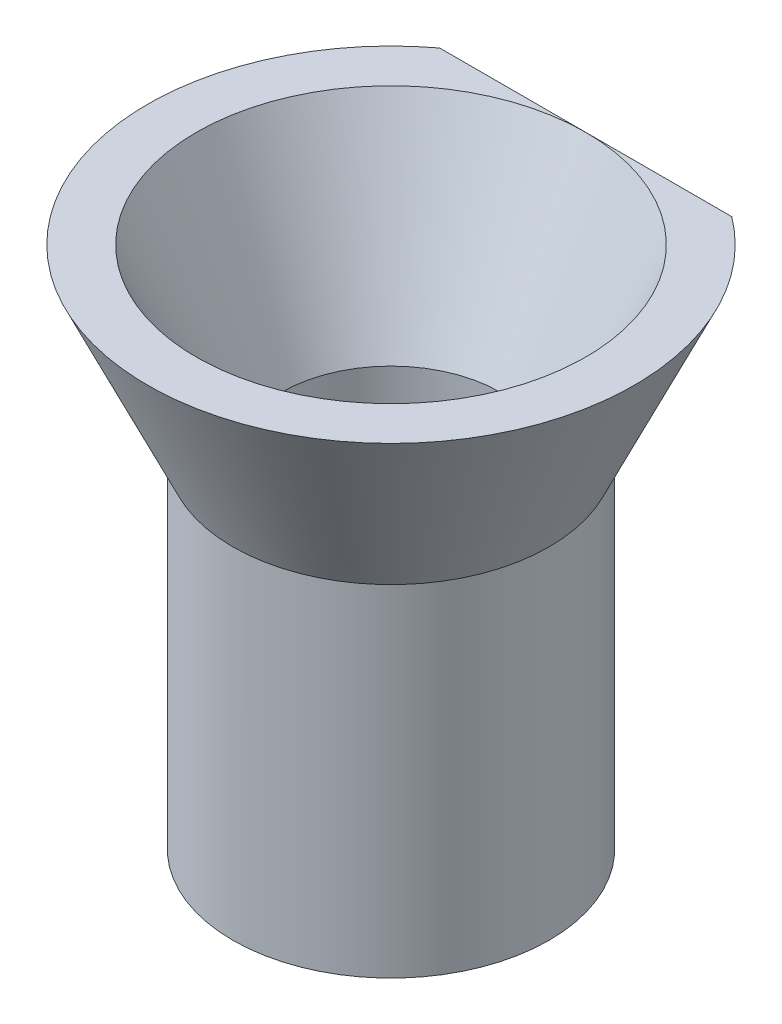
from build123d import *

# Parameters (mm, degrees)
CROQUIS3_R              = 6.5
CROQUIS3_R_2            = 4.5
SALIENTE_EXTRUIR1_DEPTH = 14
CROQUIS4_W              = 14.224697916
CROQUIS4_H              = 2.830487819
CORTAR_EXTRUIR1_DEPTH   = 7.5


with BuildPart() as part:
    # Croquis2 → Revolución1 (revolve)
    with BuildSketch(Plane.XY):
        Polygon((-4.5, 0), (-8, 7.5), (-10, 7.5), (-6.5, 0), align=None)
    revolve(axis=Axis((0, 7.5, 0), (0, -1, 0)))

    # Croquis3 → Saliente-Extruir1 (add)
    with BuildSketch(Plane.XZ):
        Circle(CROQUIS3_R)
        Circle(CROQUIS3_R_2, mode=Mode.SUBTRACT)
    extrude(amount=SALIENTE_EXTRUIR1_DEPTH)

    # Croquis4 → Cortar-Extruir1 (cut)
    with BuildSketch(Plane(origin=(0, 7.5, 0), x_dir=(1, 0, 0), z_dir=(0, 1, 0))):
        with Locations((0, 9.415243909)):
            Rectangle(CROQUIS4_W, CROQUIS4_H)
    extrude(amount=-CORTAR_EXTRUIR1_DEPTH, mode=Mode.SUBTRACT)


solid = part.part
